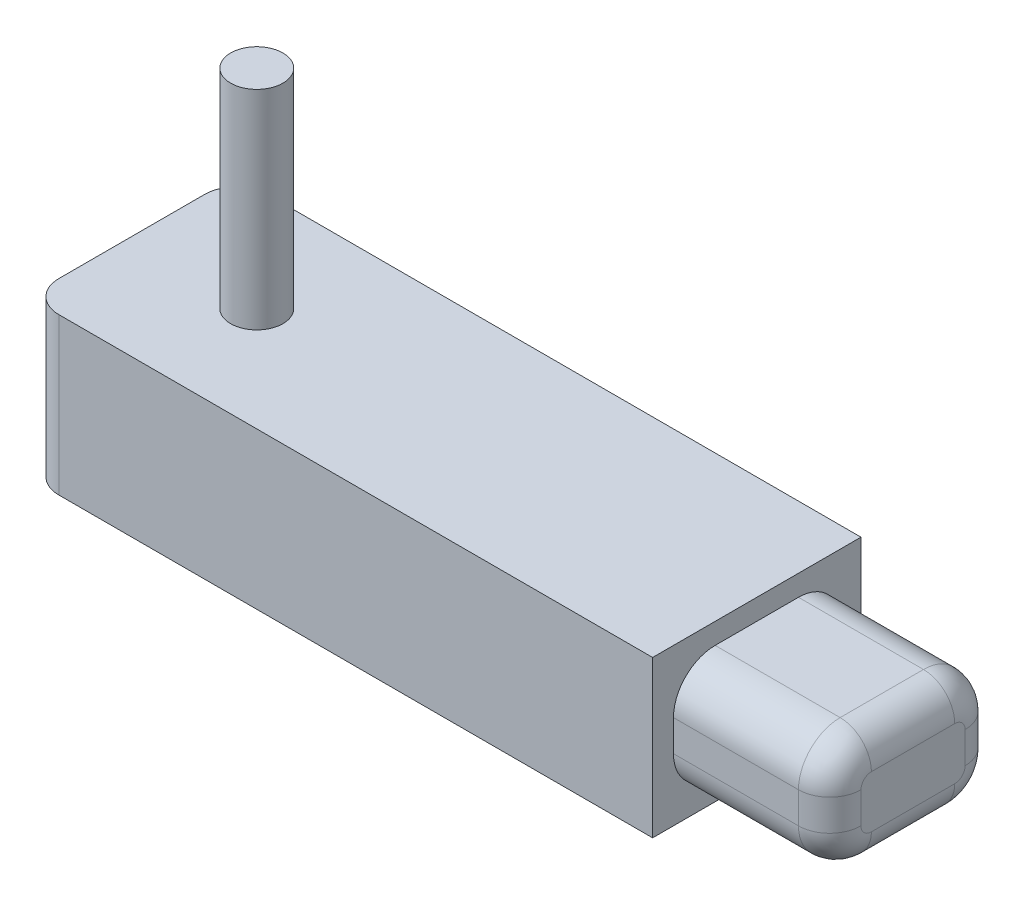
from build123d import *

# Parameters (mm, degrees)
SKETCH1_W           = 60
SKETCH1_H           = 15
BOSS_EXTRUDE2_DEPTH = 20
SKETCH4_R           = 2.509766753
BOSS_EXTRUDE3_DEPTH = 20
SKETCH5_W           = 16
SKETCH5_H           = 11
BOSS_EXTRUDE4_DEPTH = 15
FILLET2_R           = 4
FILLET3_R           = 4
FILLET6_R           = 4
FILLET7_R           = 3
FILLET8_R           = 3


with BuildPart() as part:
    # Sketch1 → Boss-Extrude2 (new body)
    with BuildSketch(Plane.XY):
        with Locations((-19.125, -0.469901236)):
            Rectangle(SKETCH1_W, SKETCH1_H)
    extrude(amount=BOSS_EXTRUDE2_DEPTH)

    # Sketch4 → Boss-Extrude3 (add)
    with BuildSketch(Plane(origin=(0, 7.030098764, 0), x_dir=(1, 0, 0), z_dir=(0, 1, 0))):
        with Locations((-37.125, -10)):
            Circle(SKETCH4_R)
    extrude(amount=BOSS_EXTRUDE3_DEPTH)

    # Sketch5 → Boss-Extrude4 (add)
    with BuildSketch(Plane(origin=(10.875, 0, 0), x_dir=(0, 0, -1), z_dir=(1, 0, 0))):
        with Locations((-10, -0.469901236)):
            Rectangle(SKETCH5_W, SKETCH5_H)
    extrude(amount=BOSS_EXTRUDE4_DEPTH)

    # Fillet2
    fillet2_edges = [part.edges().sort_by_distance(p)[0] for p in [
        (18.375, 5.030098764, 2),
    ]]
    fillet(fillet2_edges, radius=FILLET2_R)

    # Fillet3
    fillet3_edges = [part.edges().sort_by_distance(p)[0] for p in [
        (18.375, 5.030098764, 18),
    ]]
    fillet(fillet3_edges, radius=FILLET3_R)

    # Fillet6
    fillet6_edges = [part.edges().sort_by_distance(p)[0] for p in [
        (18.375, -5.969901236, 2),
        (18.375, -5.969901236, 18),
    ]]
    fillet(fillet6_edges, radius=FILLET6_R)

    # Fillet7
    fillet7_edges = [part.edges().sort_by_distance(p)[0] for p in [
        (25.875, 5.030098764, 10),
        (25.875, 3.858525889, 3.171572875),
        (25.875, -0.469901236, 18),
        (25.875, 3.858525889, 16.828427125),
        (25.875, -5.969901236, 10),
        (25.875, -0.469901236, 2),
        (25.875, -4.798328361, 3.171572875),
        (25.875, -4.798328361, 16.828427125),
    ]]
    fillet(fillet7_edges, radius=FILLET7_R)

    # Fillet8
    fillet8_edges = [part.edges().sort_by_distance(p)[0] for p in [
        (-49.125, -0.469901236, 20),
        (-49.125, -0.469901236, 0),
    ]]
    fillet(fillet8_edges, radius=FILLET8_R)


solid = part.part
